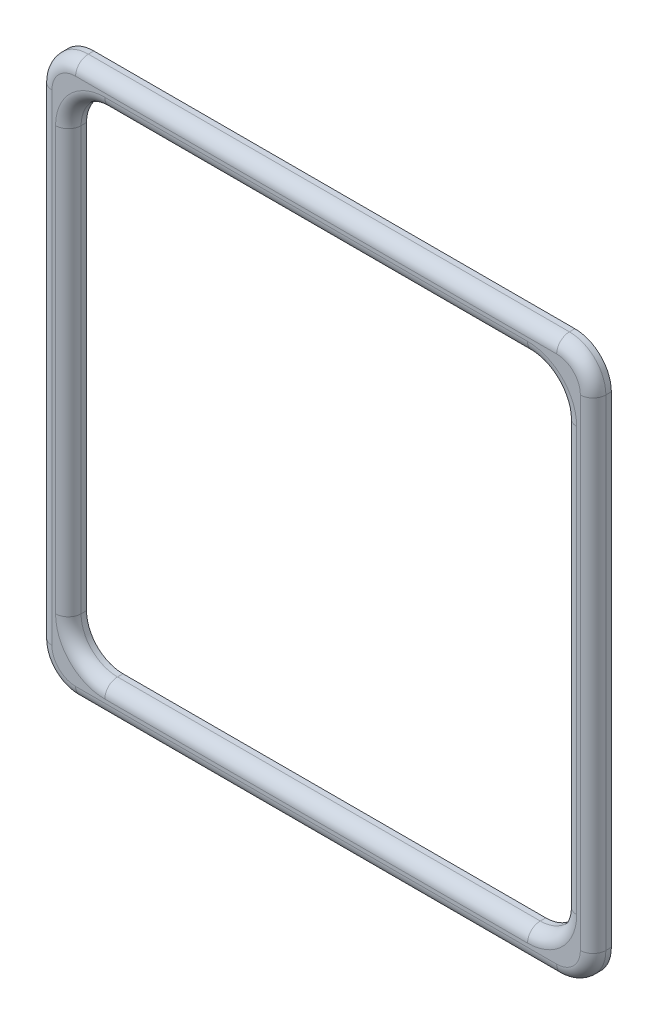
from build123d import *

# Parameters (mm, degrees)
BOSS_EXTRUDE1_DEPTH = 2.5
FILLET1_R           = 1.75


with BuildPart() as part:
    # Sketch1 → Boss-Extrude1 (new body)
    with BuildSketch(Plane.XY):
        with BuildLine():
            Line((-33, 38), (33, 38))
            ThreePointArc((33, 38), (36.535533906, 36.535533906), (38, 33))
            Line((38, 33), (38, -33))
            ThreePointArc((38, -33), (36.535533906, -36.535533906), (33, -38))
            Line((33, -38), (-33, -38))
            ThreePointArc((-33, -38), (-36.535533906, -36.535533906), (-38, -33))
            Line((-38, -33), (-38, 33))
            ThreePointArc((-38, 33), (-36.535533906, 36.535533906), (-33, 38))
        make_face()
        with BuildLine():
            Line((29, 34), (-29, 34))
            ThreePointArc((-29, 34), (-32.535533906, 32.535533906), (-34, 29))
            Line((-34, 29), (-34, -29))
            ThreePointArc((-34, -29), (-32.535533906, -32.535533906), (-29, -34))
            Line((-29, -34), (29, -34))
            ThreePointArc((29, -34), (32.535533906, -32.535533906), (34, -29))
            Line((34, -29), (34, 29))
            ThreePointArc((34, 29), (32.535533906, 32.535533906), (29, 34))
        make_face(mode=Mode.SUBTRACT)
    extrude(amount=BOSS_EXTRUDE1_DEPTH)

    # Fillet1
    fillet1_edges = [part.edges().sort_by_distance(p)[0] for p in [
        (36.535533906, -36.535533906, 2.5),
        (38, 0, 2.5),
        (36.535533906, 36.535533906, 2.5),
        (0, 38, 2.5),
        (-36.535533906, 36.535533906, 2.5),
        (-38, 0, 2.5),
        (-32.535533906, -32.535533906, 2.5),
        (0, -34, 2.5),
        (32.535533906, -32.535533906, 2.5),
        (34, 0, 2.5),
        (32.535533906, 32.535533906, 2.5),
        (0, 34, 2.5),
        (-32.535533906, 32.535533906, 2.5),
        (-34, 0, 2.5),
        (-36.535533906, -36.535533906, 2.5),
        (0, -38, 2.5),
    ]]
    fillet(fillet1_edges, radius=FILLET1_R)


solid = part.part
